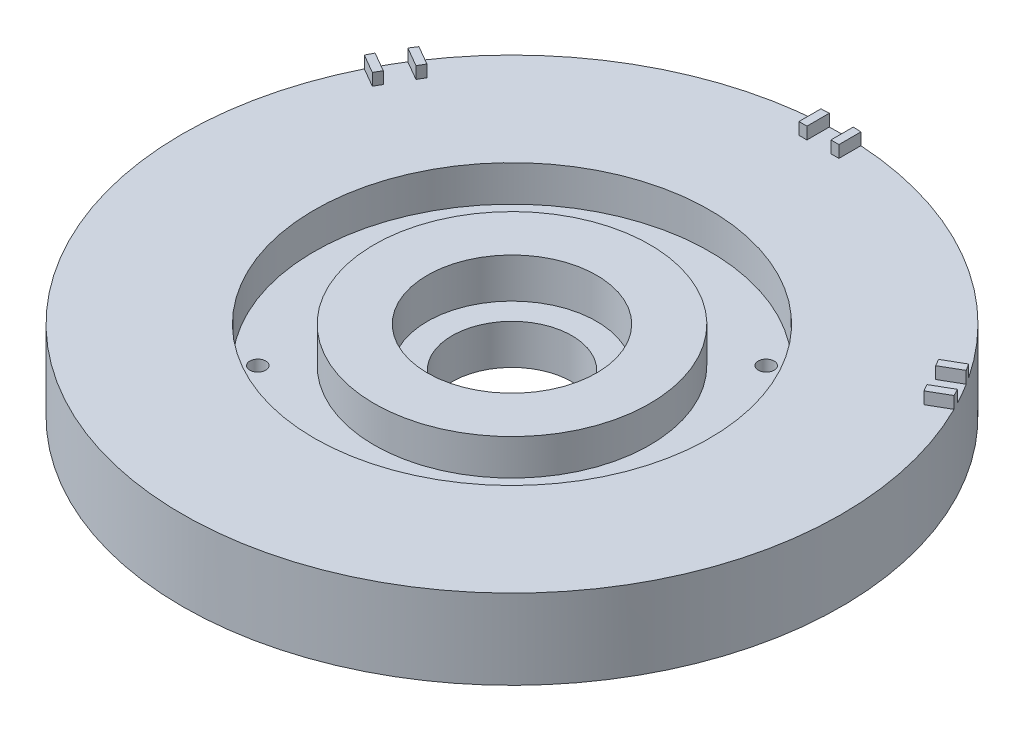
from build123d import *

# Parameters (mm, degrees)
SKETCH1_R           = 82.5
BOSS_EXTRUDE1_DEPTH = 20
SKETCH2_R           = 15
CUT_EXTRUDE1_DEPTH  = 20
SKETCH3_R           = 49.5
SKETCH3_R_2         = 34.5
CUT_EXTRUDE2_DEPTH  = 9
SKETCH4_R           = 2.5
CUT_EXTRUDE3_DEPTH  = 13
SKETCH5_R           = 2
CUT_EXTRUDE4_DEPTH  = 17
SKETCH7_R           = 21.2
SKETCH7_R_2         = 15
CUT_EXTRUDE5_DEPTH  = 10
BOSS_EXTRUDE2_DEPTH = 3


with BuildPart() as part:
    # Sketch1 → Boss-Extrude1 (new body)
    with BuildSketch(Plane(origin=(0, 0, 0), x_dir=(1, 0, 0), z_dir=(0, 1, 0))):
        Circle(SKETCH1_R)
    extrude(amount=BOSS_EXTRUDE1_DEPTH)

    # Sketch2 → Cut-Extrude1 (cut)
    with BuildSketch(Plane(origin=(0, 20, 0), x_dir=(1, 0, 0), z_dir=(0, 1, 0))):
        Circle(SKETCH2_R)
    extrude(amount=-CUT_EXTRUDE1_DEPTH, mode=Mode.SUBTRACT)

    # Sketch3 → Cut-Extrude2 (cut)
    with BuildSketch(Plane(origin=(0, 20, 0), x_dir=(1, 0, 0), z_dir=(0, 1, 0))):
        Circle(SKETCH3_R)
        Circle(SKETCH3_R_2, mode=Mode.SUBTRACT)
    extrude(amount=-CUT_EXTRUDE2_DEPTH, mode=Mode.SUBTRACT)

    # Sketch4 → Cut-Extrude3 (cut)
    with BuildSketch(Plane.XZ):
        with Locations((0, 70)):
            Circle(SKETCH4_R)
        with Locations((60.621778265, 35)):
            Circle(SKETCH4_R)
        with Locations((60.621778265, -35)):
            Circle(SKETCH4_R)
        with Locations((0, -70)):
            Circle(SKETCH4_R)
        with Locations((-60.621778265, -35)):
            Circle(SKETCH4_R)
        with Locations((-60.621778265, 35)):
            Circle(SKETCH4_R)
    extrude(amount=-CUT_EXTRUDE3_DEPTH, mode=Mode.SUBTRACT)

    # Sketch5 → Cut-Extrude4 (cut)
    with BuildSketch(Plane.XZ):
        with Locations((31.819805153, 31.819805153)):
            Circle(SKETCH5_R)
        with Locations((31.819805153, -31.819805153)):
            Circle(SKETCH5_R)
        with Locations((-31.819805153, -31.819805153)):
            Circle(SKETCH5_R)
        with Locations((-31.819805153, 31.819805153)):
            Circle(SKETCH5_R)
    extrude(amount=-CUT_EXTRUDE4_DEPTH, mode=Mode.SUBTRACT)

    # Sketch7 → Cut-Extrude5 (cut)
    with BuildSketch(Plane(origin=(0, 20, 0), x_dir=(1, 0, 0), z_dir=(0, 1, 0))):
        Circle(SKETCH7_R)
        Circle(SKETCH7_R_2, mode=Mode.SUBTRACT)
    extrude(amount=-CUT_EXTRUDE5_DEPTH, mode=Mode.SUBTRACT)

    # Sketch8 → Boss-Extrude2 (add)
    with BuildSketch(Plane(origin=(0, 20, 0), x_dir=(1, 0, 0), z_dir=(0, 1, 0))):
        with BuildLine():
            Line((-5, 82.34834546), (-5, 76.84834546))
            Line((-5, 76.84834546), (-3, 76.84834546))
            Line((-3, 76.84834546), (-3, 82.445436502))
            ThreePointArc((-3, 82.445436502), (-4.000294573, 82.402958948), (-5, 82.34834546))
        make_face()
        with BuildLine():
            Line((5, 76.84834546), (5, 82.34834546))
            ThreePointArc((5, 82.34834546), (4.000294573, 82.402958948), (3, 82.445436502))
            Line((3, 82.445436502), (3, 76.84834546))
            Line((3, 76.84834546), (5, 76.84834546))
        make_face()
        with BuildLine():
            Line((64.052619407, 42.754299749), (65.052619407, 41.022248941))
            Line((65.052619407, 41.022248941), (69.899842437, 43.820794462))
            ThreePointArc((69.899842437, 43.820794462), (69.362908509, 44.665836196), (68.815759128, 45.504299749))
            Line((68.815759128, 45.504299749), (64.052619407, 42.754299749))
        make_face()
        with BuildLine():
            Line((69.052619407, 34.094045711), (73.815759128, 36.844045711))
            ThreePointArc((73.815759128, 36.844045711), (73.363203082, 37.737122751), (72.899842437, 38.62464204))
            Line((72.899842437, 38.62464204), (68.052619407, 35.826096519))
            Line((68.052619407, 35.826096519), (69.052619407, 34.094045711))
        make_face()
        with BuildLine():
            Line((-64.052619407, 42.754299749), (-68.815759128, 45.504299749))
            ThreePointArc((-68.815759128, 45.504299749), (-69.362908509, 44.665836196), (-69.899842437, 43.820794462))
            Line((-69.899842437, 43.820794462), (-65.052619407, 41.022248941))
            Line((-65.052619407, 41.022248941), (-64.052619407, 42.754299749))
        make_face()
        with BuildLine():
            Line((-69.052619407, 34.094045711), (-73.815759128, 36.844045711))
            ThreePointArc((-73.815759128, 36.844045711), (-73.363203082, 37.737122751), (-72.899842437, 38.62464204))
            Line((-72.899842437, 38.62464204), (-68.052619407, 35.826096519))
            Line((-68.052619407, 35.826096519), (-69.052619407, 34.094045711))
        make_face()
    extrude(amount=BOSS_EXTRUDE2_DEPTH)


solid = part.part
